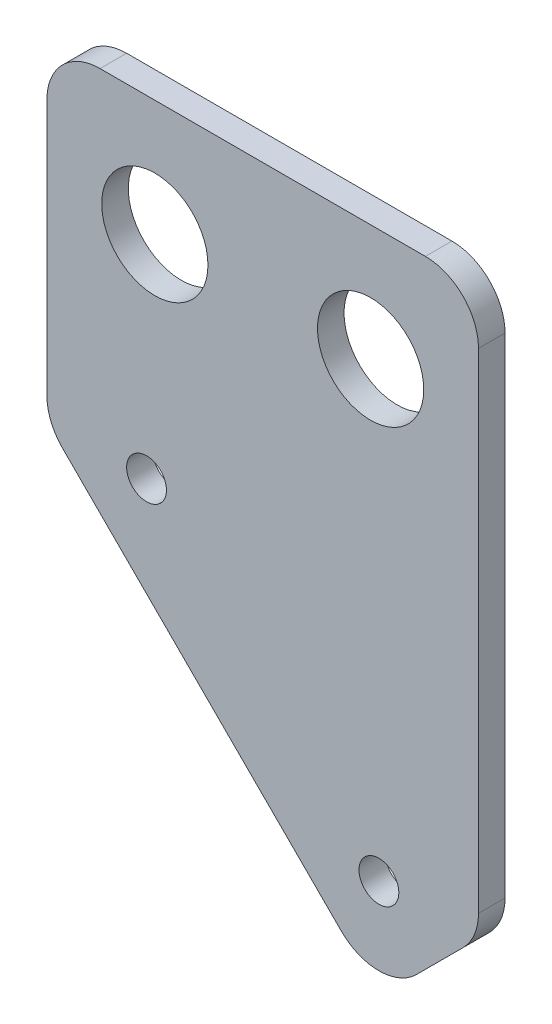
from build123d import *

# Parameters (mm, degrees)
CROQUIS1_R              = 1.5
CROQUIS1_R_2            = 4
SALIENTE_EXTRUIR1_DEPTH = 2


with BuildPart() as part:
    # Croquis1 → Saliente-Extruir1 (new body)
    with BuildSketch(Plane.XY):
        with BuildLine():
            Line((23.828427125, -18.671572875), (20.328427125, -22.171572875))
            ThreePointArc((20.328427125, -22.171572875), (17.5, -23.343145751), (14.671572875, -22.171572875))
            Line((14.671572875, -22.171572875), (-6.328427125, -1.171572875))
            ThreePointArc((-6.328427125, -1.171572875), (-7.19551813, 0.12612052), (-7.5, 1.656854249))
            Line((-7.5, 1.656854249), (-7.5, 21))
            ThreePointArc((-7.5, 21), (-6.328427125, 23.828427125), (-3.5, 25))
            Line((-3.5, 25), (21, 25))
            ThreePointArc((21, 25), (23.828427125, 23.828427125), (25, 21))
            Line((25, 21), (25, -15.843145751))
            ThreePointArc((25, -15.843145751), (24.69551813, -17.37387948), (23.828427125, -18.671572875))
        make_face()
        Circle(CROQUIS1_R, mode=Mode.SUBTRACT)
        with Locations((17.5, -17.5)):
            Circle(CROQUIS1_R, mode=Mode.SUBTRACT)
        with Locations((0.625, 16.25)):
            Circle(CROQUIS1_R_2, mode=Mode.SUBTRACT)
        with Locations((16.875, 16.25)):
            Circle(CROQUIS1_R_2, mode=Mode.SUBTRACT)
    extrude(amount=SALIENTE_EXTRUIR1_DEPTH)


solid = part.part
